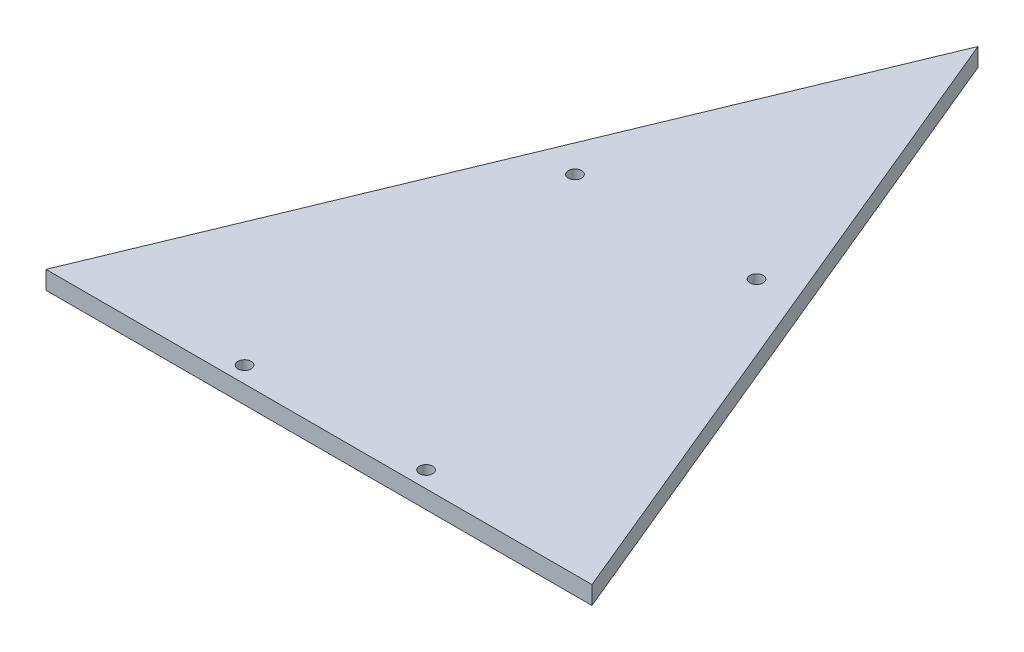
from build123d import *

# Parameters (mm, degrees)
SKETCH1_R           = 2
BOSS_EXTRUDE1_DEPTH = 5
SKETCH3_W           = 64.166552172
SKETCH3_H           = 97.438097742
BOSS_EXTRUDE2_DEPTH = 5
SKETCH4_R           = 1.825
CUT_EXTRUDE1_DEPTH  = 10


with BuildPart() as part:
    # Sketch1 → Boss-Extrude1 (new body)
    with BuildSketch(Plane(origin=(0, 0, 0), x_dir=(1, 0, 0), z_dir=(0, 1, 0))):
        Polygon((75.179761571, 0), (0, 181.5), (-75.179761571, 0), align=None)
        with Locations((27.701843901, 4.378893659)):
            Circle(SKETCH1_R, mode=Mode.SUBTRACT)
        with Locations((-27.701843901, 4.378893659)):
            Circle(SKETCH1_R, mode=Mode.SUBTRACT)
        with Locations((-27.701843901, 95.621106341)):
            Circle(SKETCH1_R, mode=Mode.SUBTRACT)
        with Locations((27.701843901, 95.621106341)):
            Circle(SKETCH1_R, mode=Mode.SUBTRACT)
    extrude(amount=BOSS_EXTRUDE1_DEPTH)

    # Sketch3 → Boss-Extrude2 (add)
    with BuildSketch(Plane(origin=(0, 5, 0), x_dir=(1, 0, 0), z_dir=(0, 1, 0))):
        with Locations((-0.392642939, 50.723354507)):
            Rectangle(SKETCH3_W, SKETCH3_H)
    extrude(amount=-BOSS_EXTRUDE2_DEPTH)

    # Sketch4 → Cut-Extrude1 (cut)
    with BuildSketch(Plane(origin=(0, 5, 0), x_dir=(1, 0, 0), z_dir=(0, 1, 0))):
        with Locations((-25, 4.5)):
            Circle(SKETCH4_R)
        with Locations((25, 4.5)):
            Circle(SKETCH4_R)
        with Locations((25, 95.5)):
            Circle(SKETCH4_R)
        with Locations((-25, 95.5)):
            Circle(SKETCH4_R)
    extrude(amount=-CUT_EXTRUDE1_DEPTH, mode=Mode.SUBTRACT)


solid = part.part
